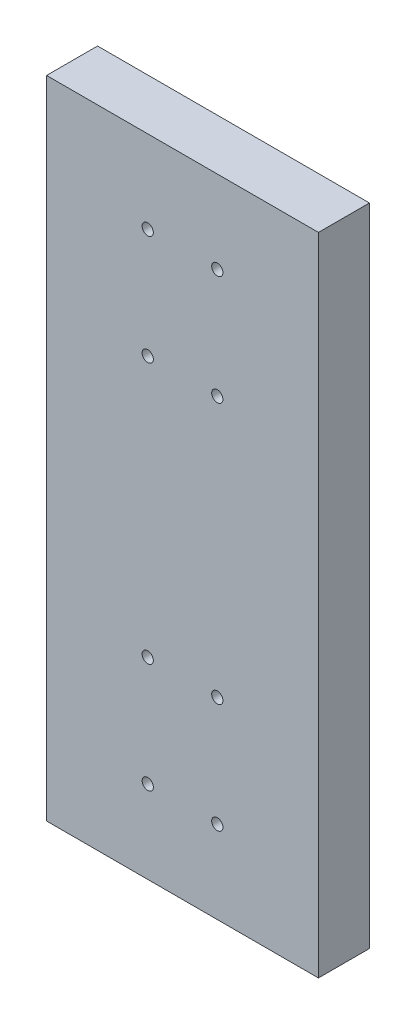
from build123d import *

# Parameters (mm, degrees)
SKETCH1_W                        = 101.6
SKETCH1_H                        = 241.3
BOSS_EXTRUDE1_DEPTH              = 19.05
TAP_DRILL_FOR_M4_HELICOIL0_D     = 4.2
TAP_DRILL_FOR_M4_HELICOIL0_DEPTH = 11.4000026
TAP_DRILL_FOR_M4_HELICOIL0_TIP   = 1.2618073


with BuildPart() as part:
    # Sketch1 → Boss-Extrude1 (new body)
    with BuildSketch(Plane(origin=(0, 4848.835870432, 0), x_dir=(1, 0, 0), z_dir=(0, 0, 1))):
        with Locations((-370.62448934, 15.409688746)):
            Rectangle(SKETCH1_W, SKETCH1_H)
    extrude(amount=BOSS_EXTRUDE1_DEPTH)

    # Tap Drill for M4 Helicoil0
    with Locations(Plane(origin=(0, 0, 19.05), x_dir=(-1, 0, 0), z_dir=(0, 0, 1))):
        with Locations((383.62448934, -4912.995559179), (357.624489341, -4912.995559179), (357.62448934, -4953.995559179), (383.62448934, -4953.995559179), (383.624489341, -4774.495559179), (383.624489341, -4815.495559179), (357.624489341, -4815.495559179), (357.62448934, -4774.495559179)):
            Hole(TAP_DRILL_FOR_M4_HELICOIL0_D / 2, depth=TAP_DRILL_FOR_M4_HELICOIL0_DEPTH)
            with Locations((0, 0, -(TAP_DRILL_FOR_M4_HELICOIL0_DEPTH + TAP_DRILL_FOR_M4_HELICOIL0_TIP / 2))):  # 118° drill point
                Cone(0, TAP_DRILL_FOR_M4_HELICOIL0_D / 2, TAP_DRILL_FOR_M4_HELICOIL0_TIP, mode=Mode.SUBTRACT)


solid = part.part
